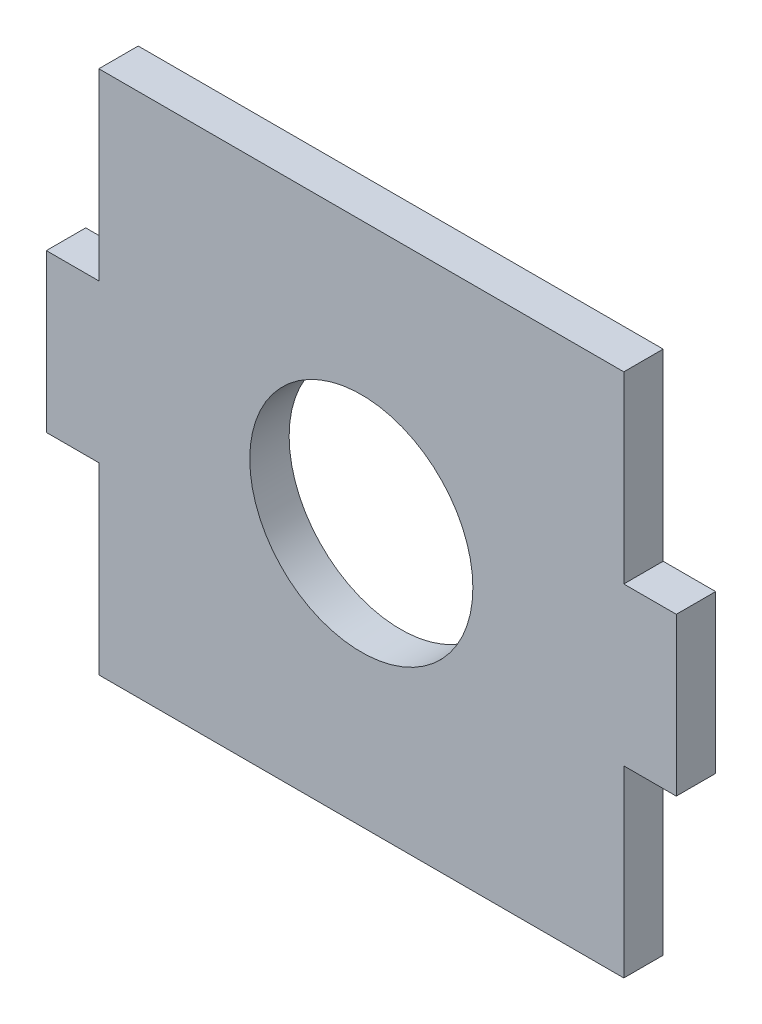
from build123d import *

# Parameters (mm, degrees)
SKETCH1_W           = 63.5
SKETCH1_H           = 63.5
SKETCH1_R           = 13.49375
SKETCH1_W_2         = 6.35
SKETCH1_H_2         = 19.05
BOSS_EXTRUDE1_DEPTH = 4.7625


with BuildPart() as part:
    # Sketch1 → Boss-Extrude1 (new body)
    with BuildSketch(Plane.XY):
        with Locations((31.75, 31.75)):
            Rectangle(SKETCH1_W, SKETCH1_H)
        with Locations((31.75, 31.75)):
            Circle(SKETCH1_R, mode=Mode.SUBTRACT)
        with Locations((-3.175, 31.75)):
            Rectangle(SKETCH1_W_2, SKETCH1_H_2)
        with Locations((66.675, 31.75)):
            Rectangle(SKETCH1_W_2, SKETCH1_H_2)
    extrude(amount=BOSS_EXTRUDE1_DEPTH)


solid = part.part
